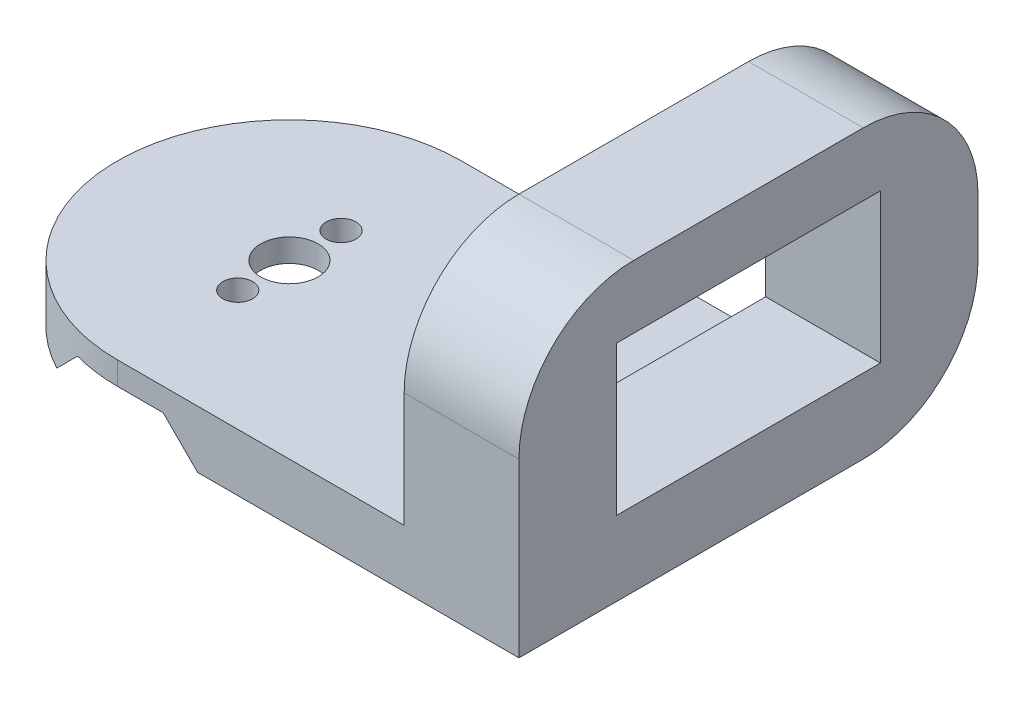
from build123d import *

# Parameters (mm, degrees)
SKETCH1_R           = 2.5
SKETCH1_R_2         = 1.3
BOSS_EXTRUDE1_DEPTH = 5
SKETCH2_W           = 40
SKETCH2_H           = 25
BOSS_EXTRUDE2_DEPTH = 10
SKETCH3_W           = 23
SKETCH3_H           = 13
CUT_EXTRUDE1_DEPTH  = 8
SKETCH3_3_R         = 1.05
CUT_EXTRUDE2_DEPTH  = 8
SKETCH3_4_W         = 23
SKETCH3_4_H         = 13
CUT_EXTRUDE3_DEPTH  = 54.38539126
FILLET1_R           = 10
CUT_EXTRUDE4_DEPTH  = 59.736700622


with BuildPart() as part:
    # Sketch1 → Boss-Extrude1 (new body)
    with BuildSketch(Plane(origin=(0, 0, 0), x_dir=(1, 0, 0), z_dir=(0, 1, 0))):
        with BuildLine():
            Line((0, 15), (25, 15))
            Line((25, 15), (25, -15))
            Line((25, -15), (0, -15))
            ThreePointArc((0, -15), (-15, 0), (0, 15))
        make_face()
        Circle(SKETCH1_R, mode=Mode.SUBTRACT)
        with Locations((0, -4.5)):
            Circle(SKETCH1_R_2, mode=Mode.SUBTRACT)
        with Locations((0, 4.5)):
            Circle(SKETCH1_R_2, mode=Mode.SUBTRACT)
    extrude(amount=BOSS_EXTRUDE1_DEPTH)

    # Sketch2 → Boss-Extrude2 (add)
    with BuildSketch(Plane(origin=(25, 0, 0), x_dir=(0, 0, -1), z_dir=(1, 0, 0))):
        with Locations((5, 12.5)):
            Rectangle(SKETCH2_W, SKETCH2_H)
    extrude(amount=BOSS_EXTRUDE2_DEPTH)

    # Sketch3 → Cut-Extrude1 (cut)
    with BuildSketch(Plane(origin=(25, 0, 0), x_dir=(0, 0, -1), z_dir=(1, 0, 0))):
        with Locations((5, 13)):
            Rectangle(SKETCH3_W, SKETCH3_H)
    extrude(amount=CUT_EXTRUDE1_DEPTH, mode=Mode.SUBTRACT)

    # Sketch3_3 → Cut-Extrude2 (cut)
    with BuildSketch(Plane(origin=(25, 0, 0), x_dir=(0, 0, -1), z_dir=(1, 0, 0))):
        with Locations((-9, 13)):
            Circle(SKETCH3_3_R)
        with Locations((19, 13)):
            Circle(SKETCH3_3_R)
    extrude(amount=CUT_EXTRUDE2_DEPTH, mode=Mode.SUBTRACT)

    # Sketch3_4 → Cut-Extrude3 (cut, through all)
    with BuildSketch(Plane(origin=(25, 0, 0), x_dir=(0, 0, -1), z_dir=(1, 0, 0))):
        with Locations((5, 13)):
            Rectangle(SKETCH3_4_W, SKETCH3_4_H)
    extrude(amount=CUT_EXTRUDE3_DEPTH, mode=Mode.SUBTRACT)

    # Fillet1
    fillet1_edges = [part.edges().sort_by_distance(p)[0] for p in [
        (30, 0, -25),
        (30, 25, -25),
        (30, 25, 15),
    ]]
    fillet(fillet1_edges, radius=FILLET1_R)

    # Sketch4 → Cut-Extrude4 (cut, through all)
    with BuildSketch(Plane.XY.offset(15)):
        Polygon((7, 0), (4, 3), (-4, 3), (-7, 0), align=None)
    extrude(amount=-CUT_EXTRUDE4_DEPTH, mode=Mode.SUBTRACT)


solid = part.part
